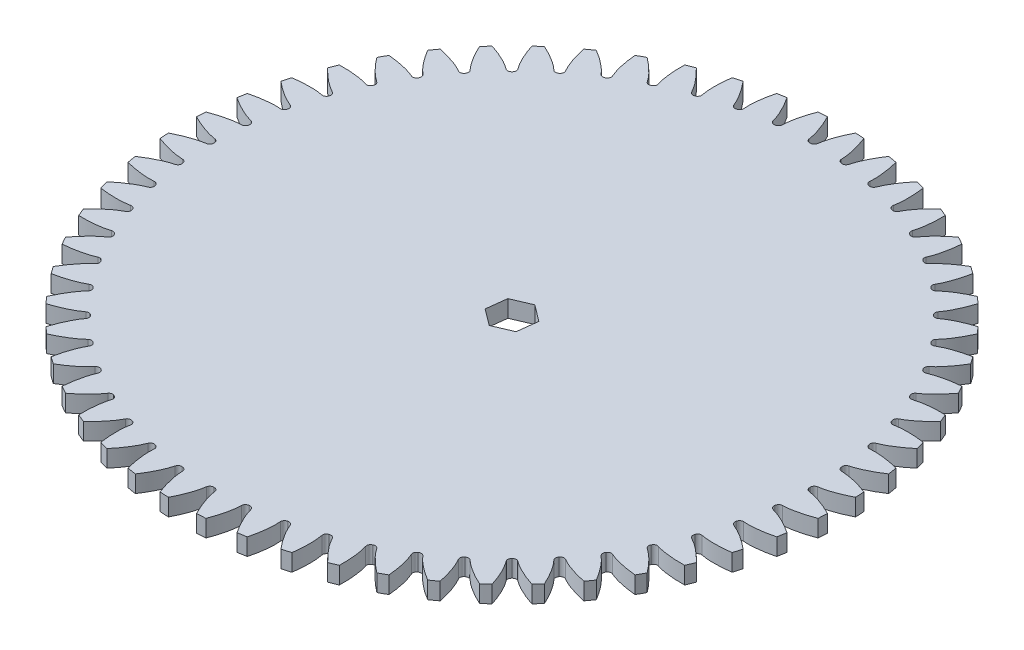
from build123d import *

# Parameters (mm, degrees)
SKETCH1_R                = 122.766666667
BOSS_EXTRUDE1_DEPTH      = 6.35
CUT_EXTRUDE1_DEPTH       = 6.35
FILLET1_R                = 1.420304652
CIRPATTERN2_COUNT        = 56
FILLET1_OF_CIRPATTERN2_R = 1.420304652
CUT_EXTRUDE2_REACH       = 8.35


with BuildPart() as part:
    # Sketch1 → Boss-Extrude1 (new body)
    with BuildSketch(Plane(origin=(0, 0, 0), x_dir=(1, 0, 0), z_dir=(0, 1, 0))):
        Circle(SKETCH1_R)
    extrude(amount=BOSS_EXTRUDE1_DEPTH)

    # Sketch2 → Cut-Extrude1 (cut)
    with BuildSketch(Plane(origin=(0, 6.35, 0), x_dir=(1, 0, 0), z_dir=(0, 1, 0))):
        with BuildLine():
            Line((111.375274828, 1.464173644), (110.94607993, 1.458531316))
            ThreePointArc((110.94607993, 1.458531316), (110.955666667, 0), (110.94607993, -1.458531316))
            Line((110.94607993, -1.458531316), (111.375274828, -1.464173644))
            add(Edge.make_bspline(
                [(111.375274828, -1.464173644), (111.392960015, -1.464579592), (111.442555077, -1.466255389), (111.536287016, -1.471545252), (111.689190037, -1.483191492), (111.883942735, -1.502463468), (112.135573963, -1.532465407), (112.431870128, -1.574361473), (112.757342654, -1.627273559), (113.111264757, -1.692258719), (113.464179888, -1.763654861), (113.816053059, -1.840990224), (114.166402059, -1.92354502), (114.590565538, -2.030070217), (115.098856664, -2.166875545), (115.692458391, -2.340012124), (116.365051392, -2.551999349), (117.049810283, -2.784783243), (117.722994417, -3.027597481), (118.402402529, -3.288770477), (119.059228943, -3.552692714), (119.740659582, -3.843088216), (120.369238516, -4.119402008), (121.072537365, -4.44700197), (121.639831761, -4.716636631), (122.225038956, -5.010226055), (122.509743942, -5.155341171), (122.655195281, -5.23044119)],
                knots=[0, 0, 0, 0, 0, 0.005376749, 0.015083688, 0.02853182, 0.04661014, 0.064854849, 0.092110526, 0.119476176, 0.146842496, 0.174208854, 0.201574956, 0.228941013, 0.256307345, 0.307035032, 0.361767352, 0.416499661, 0.471231937, 0.525964282, 0.580696616, 0.635428982, 0.690161387, 0.744893688, 0.799626082, 0.854358407, 0.909090914, 0.909090914, 0.909090914, 0.909090914, 0.909090914], degree=4))
            ThreePointArc((122.655195281, -5.23044119), (122.766666667, 0), (122.655195281, 5.23044119))
            add(Edge.make_bspline(
                [(111.375274828, 1.464173644), (111.392960015, 1.464579592), (111.442555077, 1.466255389), (111.536287016, 1.471545252), (111.689190037, 1.483191492), (111.883942735, 1.502463468), (112.135573963, 1.532465407), (112.431870128, 1.574361473), (112.757342654, 1.627273559), (113.111264757, 1.692258719), (113.464179888, 1.763654861), (113.816053059, 1.840990224), (114.166402059, 1.92354502), (114.590565538, 2.030070217), (115.098856664, 2.166875545), (115.692458391, 2.340012124), (116.365051392, 2.551999349), (117.049810283, 2.784783243), (117.722994417, 3.027597481), (118.402402529, 3.288770477), (119.059228943, 3.552692714), (119.740659582, 3.843088216), (120.369238516, 4.119402008), (121.072537365, 4.44700197), (121.639831761, 4.716636631), (122.225038956, 5.010226055), (122.509743942, 5.155341171), (122.655195281, 5.23044119)],
                knots=[0, 0, 0, 0, 0, 0.005376749, 0.015083688, 0.02853182, 0.04661014, 0.064854849, 0.092110526, 0.119476176, 0.146842496, 0.174208854, 0.201574956, 0.228941013, 0.256307345, 0.307035032, 0.361767352, 0.416499661, 0.471231937, 0.525964282, 0.580696616, 0.635428982, 0.690161387, 0.744893688, 0.799626082, 0.854358407, 0.909090914, 0.909090914, 0.909090914, 0.909090914, 0.909090914], degree=4))
        make_face()
    cut_extrude1 = extrude(amount=-CUT_EXTRUDE1_DEPTH, mode=Mode.SUBTRACT)

    # Fillet1
    fillet1_edges = [part.edges().sort_by_distance(p)[0] for p in [
        (110.94607993, 3.175, 1.458531316),
        (110.94607993, 3.175, -1.458531316),
    ]]
    fillet(fillet1_edges, radius=FILLET1_R)

    # CirPattern2: Cut-Extrude1 ×56 about axis
    cirpattern2_axis = Axis((0, 6.35, 0), (0, -1, 0))
    for i in range(1, CIRPATTERN2_COUNT):
        add(cut_extrude1.rotate(cirpattern2_axis, i * 360 / CIRPATTERN2_COUNT), mode=Mode.SUBTRACT)

    # Fillet1 of CirPattern2
    fillet1_of_cirpattern2_edges = [part.edges().sort_by_distance(p)[0] for p in [
        (110.085170572, 3.175, 13.871380092),
        (110.411777961, 3.175, 10.972659338),
        (107.83987632, 3.175, 26.109788216),
        (108.488983822, 3.175, 23.265862434),
        (104.238433054, 3.175, 38.019850603),
        (105.201877764, 3.175, 35.266483811),
        (99.326131012, 3.175, 49.451791309),
        (100.591797054, 3.175, 46.823608692),
        (93.164745242, 3.175, 60.261847047),
        (94.716716131, 3.175, 57.791899526),
        (85.831758745, 3.175, 70.314075094),
        (87.650517547, 3.175, 68.033423692),
        (77.419388081, 3.175, 79.482062849),
        (79.482062849, 3.175, 77.419388081),
        (68.033423692, 3.175, 87.650517547),
        (70.314075094, 3.175, 85.831758745),
        (57.791899526, 3.175, 94.716716131),
        (60.261847047, 3.175, 93.164745242),
        (46.823608692, 3.175, 100.591797054),
        (49.451791309, 3.175, 99.326131012),
        (35.266483811, 3.175, 105.201877764),
        (38.019850603, 3.175, 104.238433054),
        (23.265862434, 3.175, 108.488983822),
        (26.109788216, 3.175, 107.83987632),
        (10.972659338, 3.175, 110.411777961),
        (13.871380092, 3.175, 110.085170572),
        (-1.458531316, 3.175, 110.94607993),
        (1.458531316, 3.175, 110.94607993),
        (-13.871380092, 3.175, 110.085170572),
        (-10.972659338, 3.175, 110.411777961),
        (-26.109788216, 3.175, 107.83987632),
        (-23.265862434, 3.175, 108.488983822),
        (-38.019850603, 3.175, 104.238433054),
        (-35.266483811, 3.175, 105.201877764),
        (-49.451791309, 3.175, 99.326131012),
        (-46.823608692, 3.175, 100.591797054),
        (-60.261847047, 3.175, 93.164745242),
        (-57.791899526, 3.175, 94.716716131),
        (-70.314075094, 3.175, 85.831758745),
        (-68.033423692, 3.175, 87.650517547),
        (-79.482062849, 3.175, 77.419388081),
        (-77.419388081, 3.175, 79.482062849),
        (-87.650517547, 3.175, 68.033423692),
        (-85.831758745, 3.175, 70.314075094),
        (-94.716716131, 3.175, 57.791899526),
        (-93.164745242, 3.175, 60.261847047),
        (-100.591797054, 3.175, 46.823608692),
        (-99.326131012, 3.175, 49.451791309),
        (-105.201877764, 3.175, 35.266483811),
        (-104.238433054, 3.175, 38.019850603),
        (-108.488983822, 3.175, 23.265862434),
        (-107.83987632, 3.175, 26.109788216),
        (-110.411777961, 3.175, 10.972659338),
        (-110.085170572, 3.175, 13.871380092),
        (-110.94607993, 3.175, -1.458531316),
        (-110.94607993, 3.175, 1.458531316),
        (-110.085170572, 3.175, -13.871380092),
        (-110.411777961, 3.175, -10.972659338),
        (-107.83987632, 3.175, -26.109788216),
        (-108.488983822, 3.175, -23.265862434),
        (-104.238433054, 3.175, -38.019850603),
        (-105.201877764, 3.175, -35.266483811),
        (-99.326131012, 3.175, -49.451791309),
        (-100.591797054, 3.175, -46.823608692),
        (-93.164745242, 3.175, -60.261847047),
        (-94.716716131, 3.175, -57.791899526),
        (-85.831758745, 3.175, -70.314075094),
        (-87.650517547, 3.175, -68.033423692),
        (-77.419388081, 3.175, -79.482062849),
        (-79.482062849, 3.175, -77.419388081),
        (-68.033423692, 3.175, -87.650517547),
        (-70.314075094, 3.175, -85.831758745),
        (-57.791899526, 3.175, -94.716716131),
        (-60.261847047, 3.175, -93.164745242),
        (-46.823608692, 3.175, -100.591797054),
        (-49.451791309, 3.175, -99.326131012),
        (-35.266483811, 3.175, -105.201877764),
        (-38.019850603, 3.175, -104.238433054),
        (-23.265862434, 3.175, -108.488983822),
        (-26.109788216, 3.175, -107.83987632),
        (-10.972659338, 3.175, -110.411777961),
        (-13.871380092, 3.175, -110.085170572),
        (1.458531316, 3.175, -110.94607993),
        (-1.458531316, 3.175, -110.94607993),
        (13.871380092, 3.175, -110.085170572),
        (10.972659338, 3.175, -110.411777961),
        (26.109788216, 3.175, -107.83987632),
        (23.265862434, 3.175, -108.488983822),
        (38.019850603, 3.175, -104.238433054),
        (35.266483811, 3.175, -105.201877764),
        (49.451791309, 3.175, -99.326131012),
        (46.823608692, 3.175, -100.591797054),
        (60.261847047, 3.175, -93.164745242),
        (57.791899526, 3.175, -94.716716131),
        (70.314075094, 3.175, -85.831758745),
        (68.033423692, 3.175, -87.650517547),
        (79.482062849, 3.175, -77.419388081),
        (77.419388081, 3.175, -79.482062849),
        (87.650517547, 3.175, -68.033423692),
        (85.831758745, 3.175, -70.314075094),
        (94.716716131, 3.175, -57.791899526),
        (93.164745242, 3.175, -60.261847047),
        (100.591797054, 3.175, -46.823608692),
        (99.326131012, 3.175, -49.451791309),
        (105.201877764, 3.175, -35.266483811),
        (104.238433054, 3.175, -38.019850603),
        (108.488983822, 3.175, -23.265862434),
        (107.83987632, 3.175, -26.109788216),
        (110.411777961, 3.175, -10.972659338),
        (110.085170572, 3.175, -13.871380092),
    ]]
    fillet(fillet1_of_cirpattern2_edges, radius=FILLET1_OF_CIRPATTERN2_R)

    # Sketch3 → Cut-Extrude2 (cut, up to next)
    with BuildSketch(Plane(origin=(0, 6.35, 0), x_dir=(1, 0, 0), z_dir=(0, 1, 0)), mode=Mode.PRIVATE) as cut_extrude2_sk1:
        Polygon((-0.908203885, -7.57136626), (6.10289358, -4.572210766), (7.011097465, 2.999155494), (0.908203885, 7.57136626), (-6.10289358, 4.572210766), (-7.011097465, -2.999155494), align=None)
    cut_extrude2_tool1 = extrude(cut_extrude2_sk1.sketch, amount=-CUT_EXTRUDE2_REACH, mode=Mode.PRIVATE) & part.part
    add(cut_extrude2_tool1.solids().sort_by_distance((0, 6.35, 0))[0], mode=Mode.SUBTRACT)


solid = part.part
